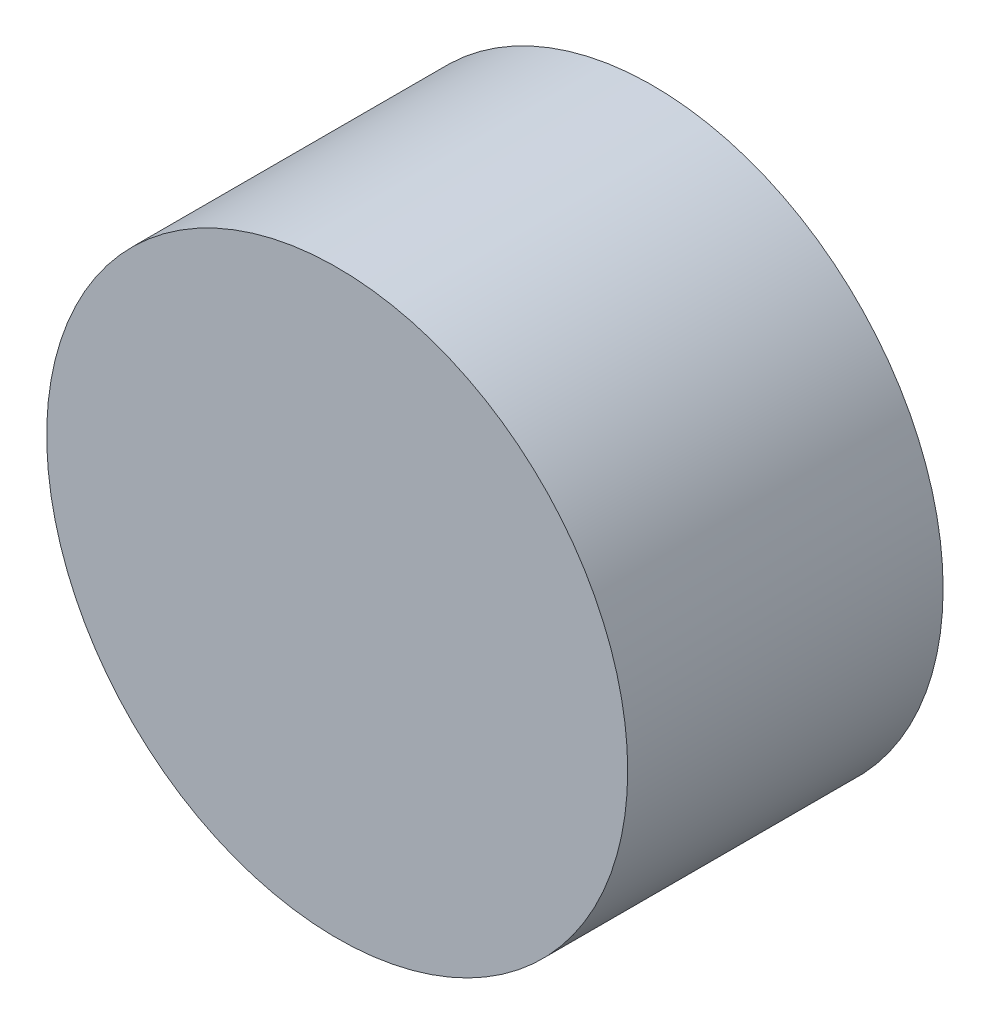
from build123d import *

# Parameters (mm, degrees)
ESQUISSE1_R             = 17.5
BOSS_EXTRU_1_DEPTH      = 19
ESQUISSE2_R             = 16.5
ENL_V_MAT_EXTRU_1_DEPTH = 15


with BuildPart() as part:
    # Esquisse1 → Boss.-Extru.1 (new body)
    with BuildSketch(Plane.XY):
        with Locations((86.602540378, -15)):
            Circle(ESQUISSE1_R)
    extrude(amount=-BOSS_EXTRU_1_DEPTH)

    # Esquisse2 → Enlèv. mat.-Extru.1 (cut)
    with BuildSketch(Plane(origin=(0, 0, -19), x_dir=(-1, 0, 0), z_dir=(0, 0, -1))):
        with Locations((-86.602540378, -15)):
            Circle(ESQUISSE2_R)
    extrude(amount=-ENL_V_MAT_EXTRU_1_DEPTH, mode=Mode.SUBTRACT)


solid = part.part
